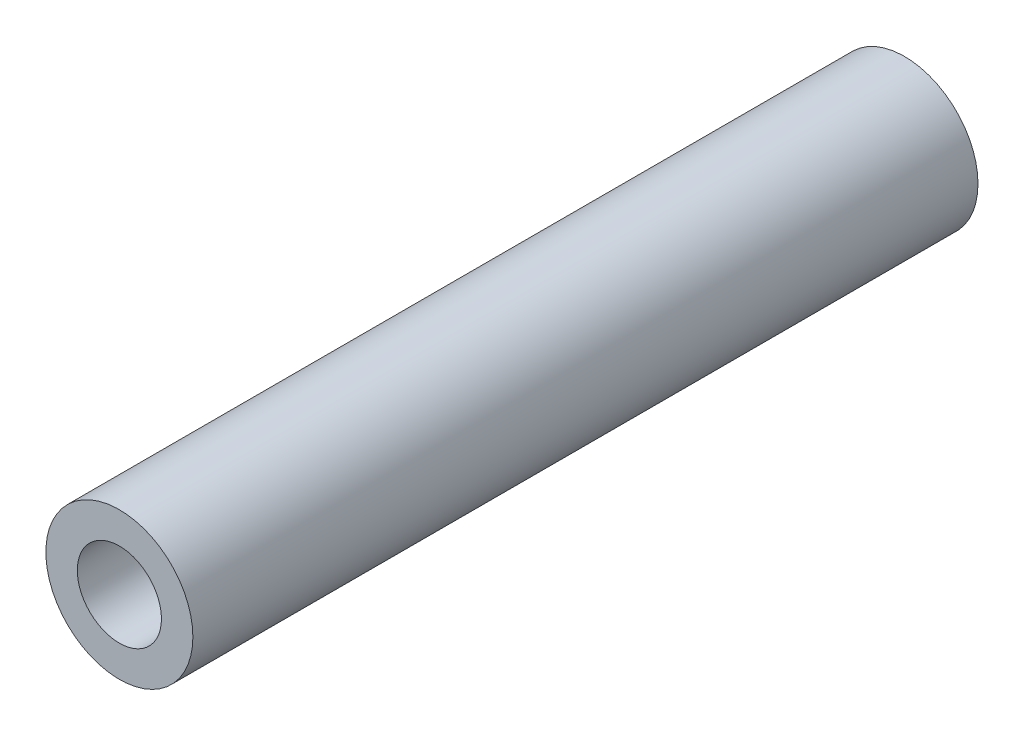
from build123d import *

# Parameters (mm, degrees)
SKETCH1_R           = 4.63
SKETCH1_R_2         = 2.65
BOSS_EXTRUDE1_DEPTH = 49.45


with BuildPart() as part:
    # Sketch1 → Boss-Extrude1 (new body)
    with BuildSketch(Plane.XY.offset(16.35)):
        with Locations((1803.99117355, -1743.849409116)):
            Circle(SKETCH1_R)
        with Locations((1803.99117355, -1743.849409116)):
            Circle(SKETCH1_R_2, mode=Mode.SUBTRACT)
    extrude(amount=BOSS_EXTRUDE1_DEPTH)


solid = part.part
